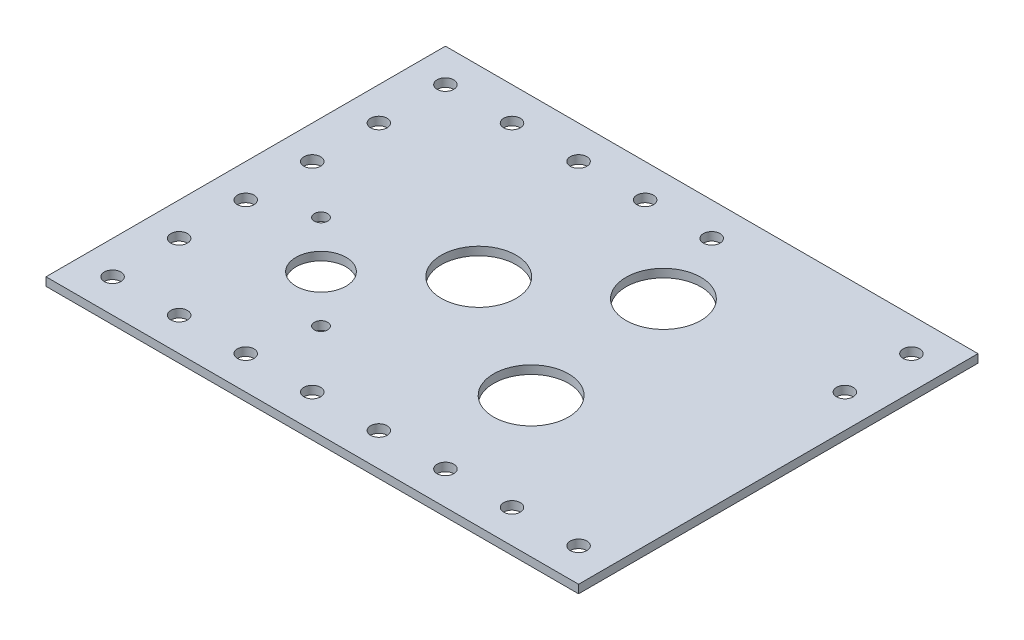
from build123d import *

# Parameters (mm, degrees)
SKETCH1_W           = 203.2
SKETCH1_H           = 152.4
BOSS_EXTRUDE1_DEPTH = 3.175
SKETCH5_R           = 9.5504
SKETCH5_R_2         = 2.54
CUT_EXTRUDE4_DEPTH  = 4.7625
SKETCH6_R           = 14.29004
CUT_EXTRUDE5_DEPTH  = 4.7625
SKETCH4_R           = 3.175
CUT_EXTRUDE7_DEPTH  = 5.08
SKETCH7_R           = 14.2875
CUT_EXTRUDE8_DEPTH  = 25.4


with BuildPart() as part:
    # Sketch1 → Boss-Extrude1 (new body)
    with BuildSketch(Plane(origin=(0, 0, 0), x_dir=(1, 0, 0), z_dir=(0, 1, 0))):
        with Locations((101.6, 76.2)):
            Rectangle(SKETCH1_W, SKETCH1_H)
    extrude(amount=BOSS_EXTRUDE1_DEPTH)

    # Sketch5 → Cut-Extrude4 (cut)
    with BuildSketch(Plane(origin=(0, 3.175, 0), x_dir=(1, 0, 0), z_dir=(0, 1, 0))):
        with Locations(Location((50.8, 54.1274, 0), (0, 0, 270))):  # turned: the seam where the file's is
            Circle(SKETCH5_R)
        with Locations(Location((32.8422, 72.0852, 0), (0, 0, 270))):  # turned: the seam where the file's is
            Circle(SKETCH5_R_2)
        with Locations(Location((68.7578, 36.1696, 0), (0, 0, 270))):  # turned: the seam where the file's is
            Circle(SKETCH5_R_2)
    extrude(amount=-CUT_EXTRUDE4_DEPTH, mode=Mode.SUBTRACT)

    # Sketch6 → Cut-Extrude5 (cut)
    with BuildSketch(Plane(origin=(0, 3.175, 0), x_dir=(1, 0, 0), z_dir=(0, 1, 0))):
        with Locations(Location((82.55, 82.55, 0), (0, 0, 270))):  # turned: the seam where the file's is
            Circle(SKETCH6_R)
    extrude(amount=-CUT_EXTRUDE5_DEPTH, mode=Mode.SUBTRACT)

    # Sketch4 → Cut-Extrude7 (cut)
    with BuildSketch(Plane(origin=(0, 3.175, 0), x_dir=(1, 0, 0), z_dir=(0, 1, 0))):
        with Locations(Location((12.7, 12.7, 0), (0, 0, 270))):  # turned: the seam where the file's is
            Circle(SKETCH4_R)
        with Locations(Location((38.1, 12.7, 0), (0, 0, 270))):  # turned: the seam where the file's is
            Circle(SKETCH4_R)
        with Locations(Location((63.5, 12.7, 0), (0, 0, 270))):  # turned: the seam where the file's is
            Circle(SKETCH4_R)
        with Locations(Location((88.9, 12.7, 0), (0, 0, 270))):  # turned: the seam where the file's is
            Circle(SKETCH4_R)
        with Locations(Location((114.3, 12.7, 0), (0, 0, 270))):  # turned: the seam where the file's is
            Circle(SKETCH4_R)
        with Locations(Location((139.7, 12.7, 0), (0, 0, 270))):  # turned: the seam where the file's is
            Circle(SKETCH4_R)
        with Locations(Location((165.1, 12.7, 0), (0, 0, 270))):  # turned: the seam where the file's is
            Circle(SKETCH4_R)
        with Locations(Location((190.5, 12.7, 0), (0, 0, 270))):  # turned: the seam where the file's is
            Circle(SKETCH4_R)
        with Locations(Location((12.7, 38.1, 0), (0, 0, 270))):  # turned: the seam where the file's is
            Circle(SKETCH4_R)
        with Locations(Location((12.7, 63.5, 0), (0, 0, 270))):  # turned: the seam where the file's is
            Circle(SKETCH4_R)
        with Locations(Location((12.7, 88.9, 0), (0, 0, 270))):  # turned: the seam where the file's is
            Circle(SKETCH4_R)
        with Locations(Location((12.7, 114.3, 0), (0, 0, 270))):  # turned: the seam where the file's is
            Circle(SKETCH4_R)
        with Locations(Location((12.7, 139.7, 0), (0, 0, 270))):  # turned: the seam where the file's is
            Circle(SKETCH4_R)
        with Locations(Location((38.1, 139.7, 0), (0, 0, 270))):  # turned: the seam where the file's is
            Circle(SKETCH4_R)
        with Locations(Location((63.5, 139.7, 0), (0, 0, 270))):  # turned: the seam where the file's is
            Circle(SKETCH4_R)
        with Locations(Location((88.9, 139.7, 0), (0, 0, 270))):  # turned: the seam where the file's is
            Circle(SKETCH4_R)
        with Locations(Location((114.3, 139.7, 0), (0, 0, 270))):  # turned: the seam where the file's is
            Circle(SKETCH4_R)
        with Locations(Location((190.5, 114.3, 0), (0, 0, 270))):  # turned: the seam where the file's is
            Circle(SKETCH4_R)
        with Locations(Location((190.5, 139.7, 0), (0, 0, 270))):  # turned: the seam where the file's is
            Circle(SKETCH4_R)
    extrude(amount=-CUT_EXTRUDE7_DEPTH, mode=Mode.SUBTRACT)

    # Sketch7 → Cut-Extrude8 (cut)
    with BuildSketch(Plane(origin=(0, 3.175, 0), x_dir=(1, 0, 0), z_dir=(0, 1, 0))):
        with Locations(Location((125.095, 110.49, 0), (0, 0, 270))):  # turned: the seam where the file's is
            Circle(SKETCH7_R)
        with Locations(Location((131.7498, 53.34, 0), (0, 0, 270))):  # turned: the seam where the file's is
            Circle(SKETCH7_R)
    extrude(amount=-CUT_EXTRUDE8_DEPTH, mode=Mode.SUBTRACT)


solid = part.part
